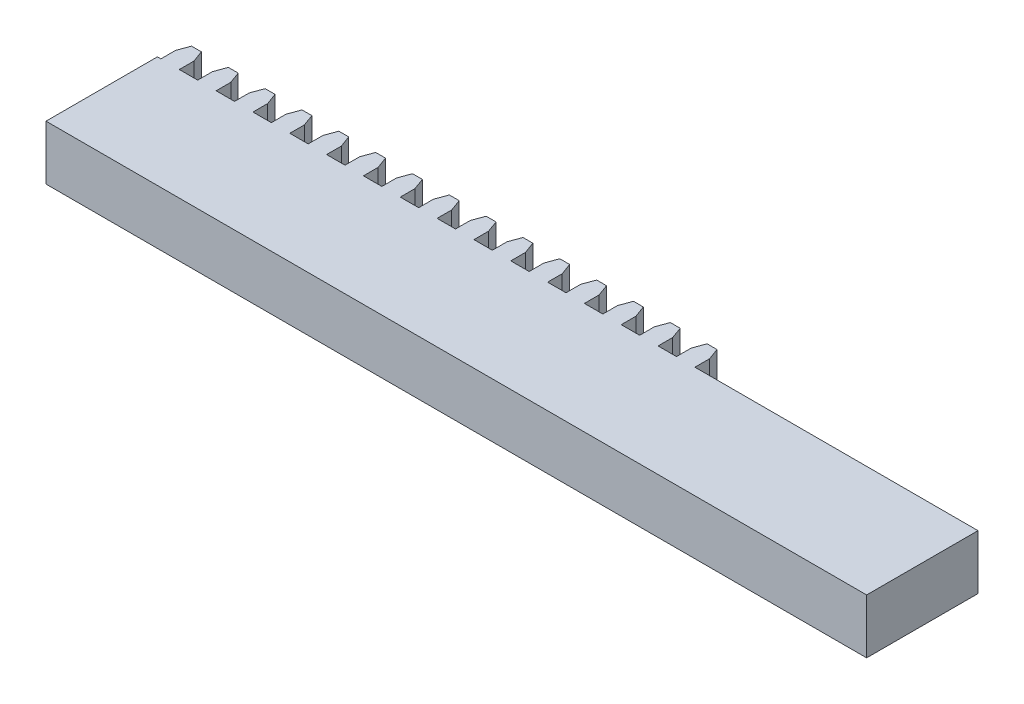
from build123d import *

# Parameters (mm, degrees)
SKETCH2_W           = 130
SKETCH2_H           = 19
BOSS_EXTRUDE1_DEPTH = 9.3
BOSS_EXTRUDE2_DEPTH = 9.3
LPATTERN1_COUNT     = 11
LPATTERN1_PITCH     = 6.283185307
LPATTERN1_COL_COUNT = 5
LPATTERN1_COL_PITCH = 6.283185307
SKETCH3_W           = 19
SKETCH3_H           = 9.3
BOSS_EXTRUDE3_DEPTH = 10


with BuildPart() as part:
    # Sketch2 → Boss-Extrude1 (new body)
    with BuildSketch(Plane(origin=(0, 0, 0), x_dir=(1, 0, 0), z_dir=(0, 1, 0))):
        with Locations((0, -9.5)):
            Rectangle(SKETCH2_W, SKETCH2_H)
    extrude(amount=BOSS_EXTRUDE1_DEPTH)

    # Sketch2_5 → Boss-Extrude2 (add)
    with BuildSketch(Plane(origin=(0, 0, 0), x_dir=(1, 0, 0), z_dir=(0, 1, 0))):
        Polygon((0.842855858, 4.499999971), (-0.842855858, 4.499999971), (-1.571175787, 2.500138124), (-1.571175787, 0), (1.570796327, 0), (1.570796327, 2.499999971), align=None)
    boss_extrude2 = extrude(amount=BOSS_EXTRUDE2_DEPTH)

    # LPattern1: Boss-Extrude2 ×11
    with Locations(*[(-i * LPATTERN1_PITCH, 0, 0) for i in range(1, LPATTERN1_COUNT)]):
        add(boss_extrude2)

    # LPattern1 col: Boss-Extrude2 ×5
    with Locations(*[(i * LPATTERN1_COL_PITCH, 0, 0) for i in range(1, LPATTERN1_COL_COUNT)]):
        add(boss_extrude2)

    # Sketch3 → Boss-Extrude3 (add)
    with BuildSketch(Plane(origin=(65, 0, 0), x_dir=(0, 0, -1), z_dir=(1, 0, 0))):
        with Locations((-9.5, 4.65)):
            Rectangle(SKETCH3_W, SKETCH3_H)
    extrude(amount=BOSS_EXTRUDE3_DEPTH)


solid = part.part
